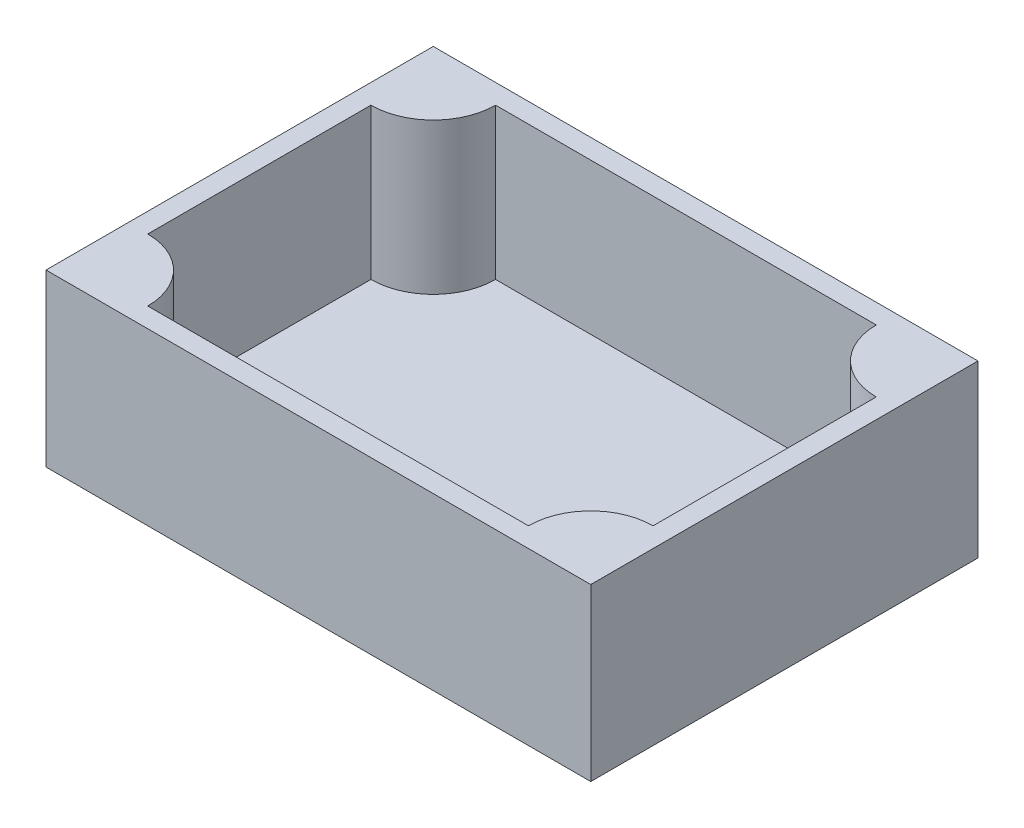
from build123d import *

# Parameters (mm, degrees)
SKETCH1_W           = 83
SKETCH1_H           = 59
BOSS_EXTRUDE1_DEPTH = 3
SKETCH2_W           = 83
SKETCH2_H           = 59
BOSS_EXTRUDE2_DEPTH = 23


with BuildPart() as part:
    # Sketch1 → Boss-Extrude1 (new body)
    with BuildSketch(Plane(origin=(0, 0, 0), x_dir=(1, 0, 0), z_dir=(0, 1, 0))):
        with Locations((41.5, 29.5)):
            Rectangle(SKETCH1_W, SKETCH1_H)
    extrude(amount=BOSS_EXTRUDE1_DEPTH)

    # Sketch2 → Boss-Extrude2 (add)
    with BuildSketch(Plane(origin=(0, 3, 0), x_dir=(1, 0, 0), z_dir=(0, 1, 0))):
        with Locations((41.5, 29.5)):
            Rectangle(SKETCH2_W, SKETCH2_H)
        with BuildLine():
            Line((3, 46.5), (3, 12.5))
            ThreePointArc((3, 12.5), (9.717514421, 9.717514421), (12.5, 3))
            Line((12.5, 3), (70.5, 3))
            ThreePointArc((70.5, 3), (73.282485579, 9.717514421), (80, 12.5))
            Line((80, 12.5), (80, 46.5))
            ThreePointArc((80, 46.5), (73.282485579, 49.282485579), (70.5, 56))
            Line((70.5, 56), (12.5, 56))
            ThreePointArc((12.5, 56), (9.717514421, 49.282485579), (3, 46.5))
        make_face(mode=Mode.SUBTRACT)
    extrude(amount=BOSS_EXTRUDE2_DEPTH)


solid = part.part
